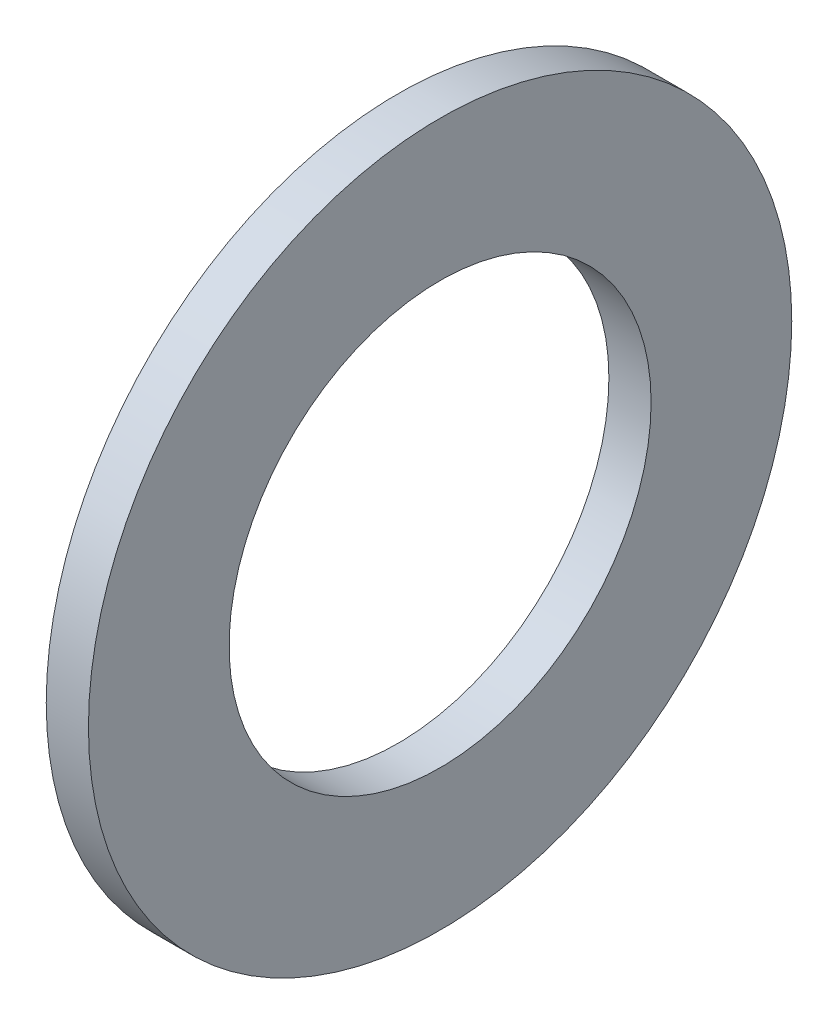
from build123d import *

# Parameters (mm, degrees)
SKETCH1_R           = 6.35
SKETCH1_R_2         = 3.81
BOSS_EXTRUDE1_DEPTH = 0.762


with BuildPart() as part:
    # Sketch1 → Boss-Extrude1 (new body)
    with BuildSketch(Plane(origin=(0, 0, 0), x_dir=(0, 0, -1), z_dir=(1, 0, 0))):
        Circle(SKETCH1_R)
        Circle(SKETCH1_R_2, mode=Mode.SUBTRACT)
    extrude(amount=BOSS_EXTRUDE1_DEPTH)


solid = part.part
